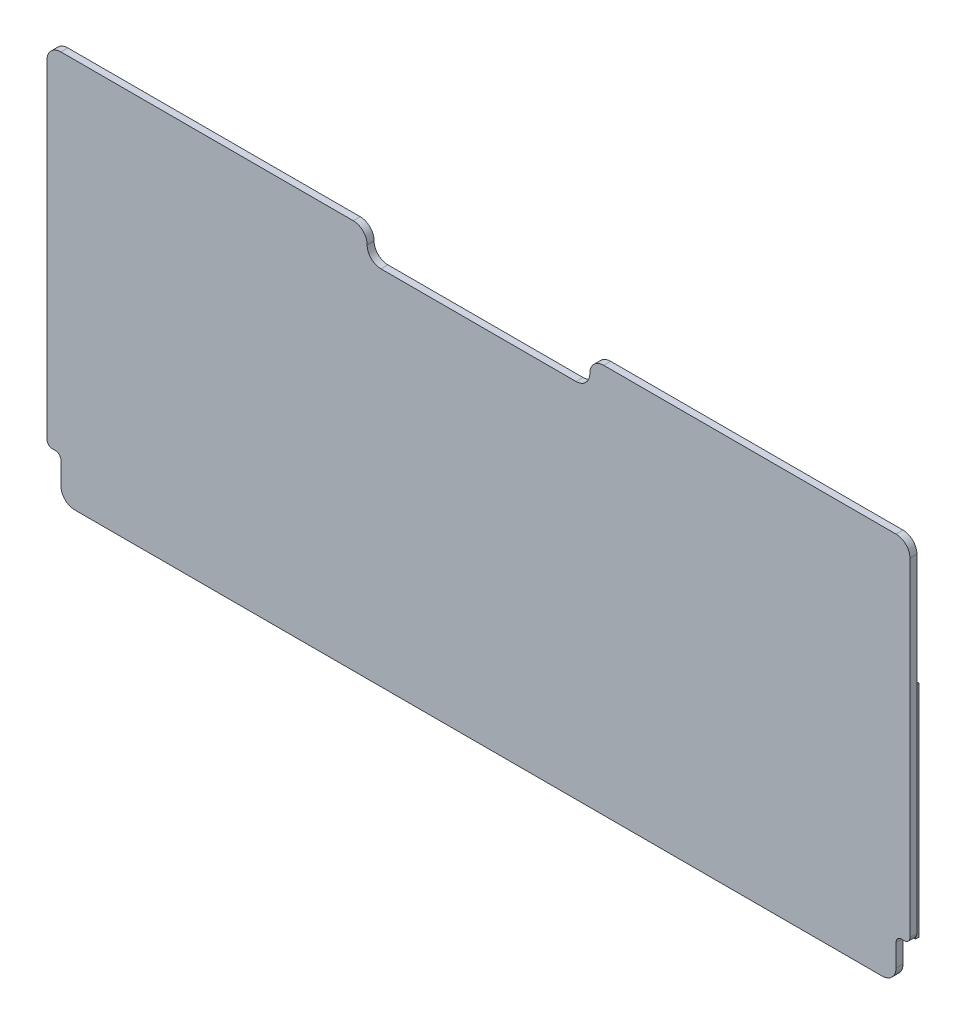
from build123d import *

# Parameters (mm, degrees)
BOSS_EXTRUDE1_DEPTH = 3.175
SKETCH2_W           = 11.43
SKETCH2_H           = 100.33
BOSS_EXTRUDE2_DEPTH = 1.5875


with BuildPart() as part:
    # Sketch1 → Boss-Extrude1 (new body)
    with BuildSketch(Plane.XY):
        with BuildLine():
            Line((-50.8, 171.390190343), (-50.8, 171.509809657))
            ThreePointArc((-50.8, 171.509809657), (-52.642354096, 175.957645904), (-57.090190343, 177.8))
            Line((-57.090190343, 177.8), (-190.5, 177.8))
            ThreePointArc((-190.5, 177.8), (-194.990128061, 175.940128061), (-196.85, 171.45))
            Line((-196.85, 171.45), (-196.85, 21.59))
            ThreePointArc((-196.85, 21.59), (-196.106051224, 19.793948776), (-194.31, 19.05))
            Line((-194.31, 19.05), (-193.04, 19.05))
            ThreePointArc((-193.04, 19.05), (-191.243948776, 18.306051224), (-190.5, 16.51))
            Line((-190.5, 16.51), (-190.5, 6.35))
            ThreePointArc((-190.5, 6.35), (-188.640128061, 1.859871939), (-184.15, 0))
            Line((-184.15, 0), (184.15, 0))
            ThreePointArc((184.15, 0), (188.640128061, 1.859871939), (190.5, 6.35))
            Line((190.5, 6.35), (190.5, 16.51))
            ThreePointArc((190.5, 16.51), (191.243948776, 18.306051224), (193.04, 19.05))
            Line((193.04, 19.05), (194.31, 19.05))
            ThreePointArc((194.31, 19.05), (196.106051224, 19.793948776), (196.85, 21.59))
            Line((196.85, 21.59), (196.85, 171.45))
            ThreePointArc((196.85, 171.45), (194.990128061, 175.940128061), (190.5, 177.8))
            Line((190.5, 177.8), (57.090190343, 177.8))
            ThreePointArc((57.090190343, 177.8), (52.642354096, 175.957645904), (50.8, 171.509809657))
            Line((50.8, 171.509809657), (50.8, 171.390190343))
            ThreePointArc((50.8, 171.390190343), (48.957645904, 166.942354096), (44.509809657, 165.1))
            Line((44.509809657, 165.1), (-44.509809657, 165.1))
            ThreePointArc((-44.509809657, 165.1), (-48.957645904, 166.942354096), (-50.8, 171.390190343))
        make_face()
    extrude(amount=BOSS_EXTRUDE1_DEPTH)

    # Sketch2 → Boss-Extrude2 (add)
    with BuildSketch(Plane(origin=(0, 0, 0), x_dir=(-1, 0, 0), z_dir=(0, 0, -1))):
        with Locations((-190.5, 69.215)):
            Rectangle(SKETCH2_W, SKETCH2_H)
        with Locations((190.5, 69.215)):
            Rectangle(SKETCH2_W, SKETCH2_H)
    extrude(amount=BOSS_EXTRUDE2_DEPTH)


solid = part.part
